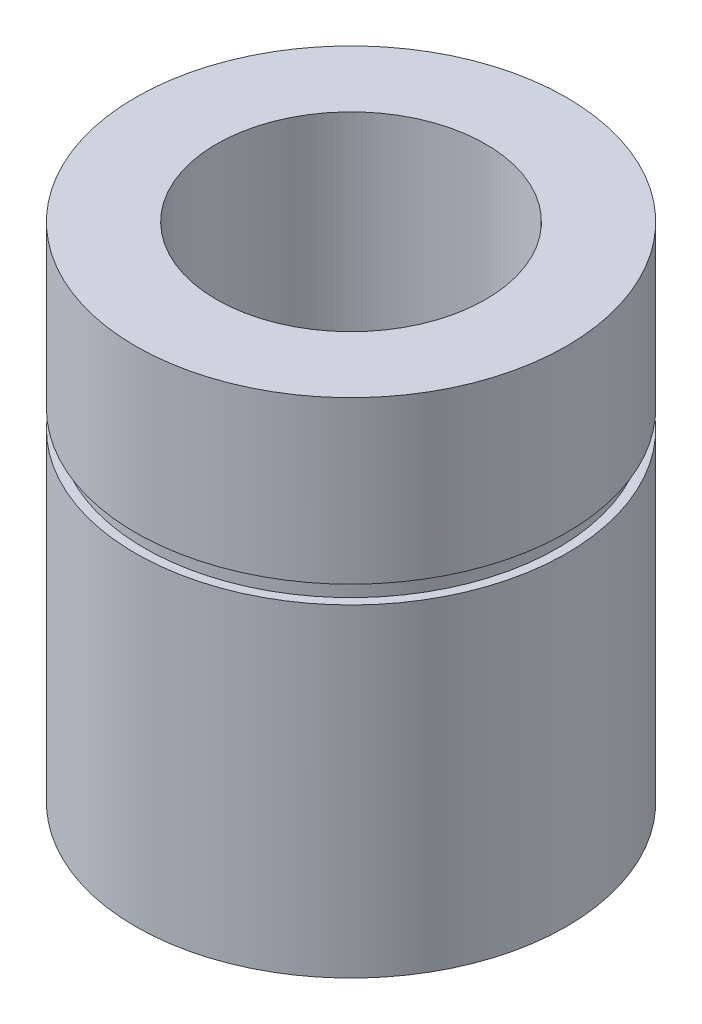
from build123d import *

# Parameters (mm, degrees)
SKIZZE1_R                       = 12
SKIZZE1_R_2                     = 7.5
AUFSATZ_LINEAR_AUSTRAGEN1_DEPTH = 28
SCHNITT_LINEAR_START            = 9
SKIZZE2_R                       = 12
SKIZZE2_R_2                     = 11.5
SCHNITT_LINEAR_AUSTRAGEN1_DEPTH = 1


with BuildPart() as part:
    # Skizze1 → Aufsatz-Linear austragen1 (new body)
    with BuildSketch(Plane(origin=(0, 0, 0), x_dir=(1, 0, 0), z_dir=(0, 1, 0))):
        Circle(SKIZZE1_R)
        Circle(SKIZZE1_R_2, mode=Mode.SUBTRACT)
    extrude(amount=AUFSATZ_LINEAR_AUSTRAGEN1_DEPTH)

    # Skizze2 → Schnitt-Linear austragen1 (cut)
    with BuildSketch(Plane.XZ.offset(-28).offset(SCHNITT_LINEAR_START)):
        Circle(SKIZZE2_R)
        Circle(SKIZZE2_R_2, mode=Mode.SUBTRACT)
    extrude(amount=SCHNITT_LINEAR_AUSTRAGEN1_DEPTH, mode=Mode.SUBTRACT)


solid = part.part
